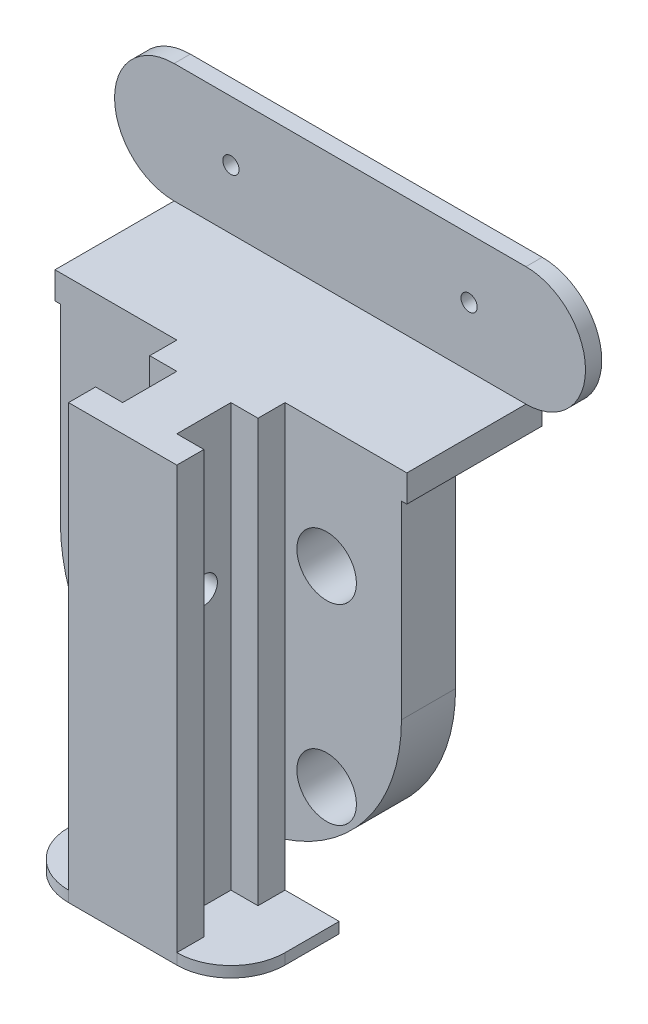
from build123d import *

# Parameters (mm, degrees)
SKETCH1_R                = 5.5
BOSS_EXTRUDE1_DEPTH      = 10
SKETCH1_3_R              = 5.5
SKETCH1_3_R_2            = 2.5
BOSS_EXTRUDE2_DEPTH      = 2
SKETCH1_4_R              = 2.5
BOSS_EXTRUDE3_DEPTH      = 5
BOSS_EXTRUDE4_DEPTH      = 5
SKETCH4_W                = 20
SKETCH4_H                = 80
BOSS_EXTRUDE5_DEPTH      = 20
SKETCH5_W                = 20
SKETCH5_H                = 2
BOSS_EXTRUDE6_DEPTH      = 10
BOSS_EXTRUDE6_DEPTH_BACK = 30
SKETCH7_W                = 5
SKETCH7_H                = 10
CUT_EXTRUDE1_DEPTH       = 78
FILLET1_R                = 10
SKETCH9_R                = 2.5
CUT_EXTRUDE2_DEPTH       = 38.5
SKETCH14_R               = 1.5
BOSS_EXTRUDE8_DEPTH      = 3


with BuildPart() as part:
    # Sketch1 → Boss-Extrude1 (new body)
    with BuildSketch(Plane.XY):
        with BuildLine():
            Line((31.5, 0), (31.5, 40))
            Line((31.5, 40), (-31.5, 40))
            Line((-31.5, 40), (-31.5, 0))
            ThreePointArc((-31.5, 0), (0, -31.5), (31.5, 0))
        make_face()
        with Locations((17.67766953, -17.67766953)):
            Circle(SKETCH1_R, mode=Mode.SUBTRACT)
        with Locations((-17.67766953, -17.67766953)):
            Circle(SKETCH1_R, mode=Mode.SUBTRACT)
        with Locations((-17.67766953, 17.67766953)):
            Circle(SKETCH1_R, mode=Mode.SUBTRACT)
        with Locations((17.67766953, 17.67766953)):
            Circle(SKETCH1_R, mode=Mode.SUBTRACT)
    extrude(amount=BOSS_EXTRUDE1_DEPTH)

    # Sketch1_3 → Boss-Extrude2 (add)
    with BuildSketch(Plane.XY):
        with Locations((17.67766953, 17.67766953)):
            Circle(SKETCH1_3_R)
        with Locations((17.67766953, 17.67766953)):
            Circle(SKETCH1_3_R_2, mode=Mode.SUBTRACT)
        with Locations((17.67766953, -17.67766953)):
            Circle(SKETCH1_3_R)
        with Locations((17.67766953, -17.67766953)):
            Circle(SKETCH1_3_R_2, mode=Mode.SUBTRACT)
        with Locations((-17.67766953, -17.67766953)):
            Circle(SKETCH1_3_R)
        with Locations((-17.67766953, -17.67766953)):
            Circle(SKETCH1_3_R_2, mode=Mode.SUBTRACT)
        with Locations((-17.67766953, 17.67766953)):
            Circle(SKETCH1_3_R)
        with Locations((-17.67766953, 17.67766953)):
            Circle(SKETCH1_3_R_2, mode=Mode.SUBTRACT)
    extrude(amount=BOSS_EXTRUDE2_DEPTH)

    # Sketch1_4 → Boss-Extrude3 (add)
    with BuildSketch(Plane.XY):
        with Locations((0, 25)):
            Circle(SKETCH1_4_R)
    extrude(amount=-BOSS_EXTRUDE3_DEPTH)

    # Sketch2 → Boss-Extrude4 (add)
    with BuildSketch(Plane(origin=(0, 40, 0), x_dir=(1, 0, 0), z_dir=(0, 1, 0))):
        Polygon((-32.5, -10), (31.5, -10), (32.5, -10), (32.5, 15), (-32.5, 15), align=None)
    extrude(amount=-BOSS_EXTRUDE4_DEPTH)

    # Sketch4 → Boss-Extrude5 (add)
    with BuildSketch(Plane.XY.offset(10)):
        Rectangle(SKETCH4_W, SKETCH4_H)
    extrude(amount=BOSS_EXTRUDE5_DEPTH)

    # Sketch5 → Boss-Extrude6 (add, two sides)
    with BuildSketch(Plane(origin=(10, 0, 0), x_dir=(0, 0, -1), z_dir=(1, 0, 0))) as boss_extrude6_sk:
        with Locations((-20, -39)):
            Rectangle(SKETCH5_W, SKETCH5_H)
    extrude(amount=BOSS_EXTRUDE6_DEPTH)
    extrude(boss_extrude6_sk.sketch, amount=-BOSS_EXTRUDE6_DEPTH_BACK)

    # Sketch7 → Cut-Extrude1 (cut)
    with BuildSketch(Plane(origin=(0, 40, 0), x_dir=(1, 0, 0), z_dir=(0, 1, 0))):
        with Locations((-7.5, -20)):
            Rectangle(SKETCH7_W, SKETCH7_H)
        with Locations((7.5, -20)):
            Rectangle(SKETCH7_W, SKETCH7_H)
    extrude(amount=-CUT_EXTRUDE1_DEPTH, mode=Mode.SUBTRACT)

    # Fillet1
    fillet1_edges = [part.edges().sort_by_distance(p)[0] for p in [
        (-20, -39, 30),
        (20, -39, 30),
    ]]
    fillet(fillet1_edges, radius=FILLET1_R)

    # Sketch9 → Cut-Extrude2 (cut, through all)
    with BuildSketch(Plane(origin=(5, 0, 0), x_dir=(0, 0, -1), z_dir=(1, 0, 0))):
        with Locations((-20, 12.5)):
            Circle(SKETCH9_R)
    extrude(amount=-CUT_EXTRUDE2_DEPTH, mode=Mode.SUBTRACT)

    # Sketch14 → Boss-Extrude8 (add)
    with BuildSketch(Plane(origin=(0, 0, -15), x_dir=(-1, 0, 0), z_dir=(0, 0, -1))):
        with BuildLine():
            Line((32.5, 62), (-32.5, 62))
            ThreePointArc((-32.5, 62), (-43.5, 51), (-32.5, 40))
            Line((-32.5, 40), (32.5, 40))
            ThreePointArc((32.5, 40), (43.5, 51), (32.5, 62))
        make_face()
        with Locations((-22, 51)):
            Circle(SKETCH14_R, mode=Mode.SUBTRACT)
        with Locations((22, 51)):
            Circle(SKETCH14_R, mode=Mode.SUBTRACT)
    extrude(amount=-BOSS_EXTRUDE8_DEPTH)


solid = part.part
